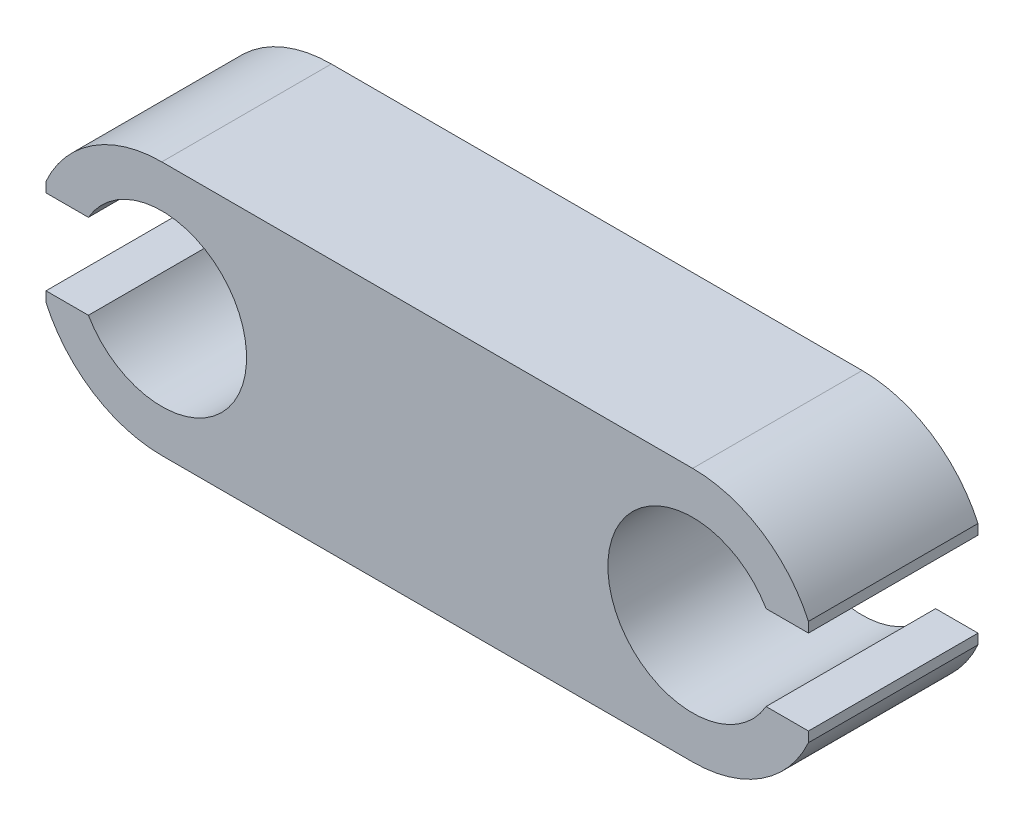
from build123d import *

# Parameters (mm, degrees)
SKETCH_1_R          = 1.5
EXTRUDE_1_DEPTH     = 2
CUT_EXTRUDE_1_DEPTH = 3


with BuildPart() as part:
    # 草图1 → 凸台-拉伸1 (new body)
    with BuildSketch(Plane.XY):
        with Locations((-3.13109105, 0)):
            Circle(SKETCH_1_R)
        with BuildLine():
            Line((3.13109105, 1.5), (-3.13109105, 1.5))
            ThreePointArc((-3.13109105, 1.5), (-2.070430878, 1.060660172), (-1.63109105, 0))
            ThreePointArc((-1.63109105, 0), (-2.070430878, -1.060660172), (-3.13109105, -1.5))
            Line((-3.13109105, -1.5), (3.13109105, -1.5))
            ThreePointArc((3.13109105, -1.5), (1.63109105, 0), (3.13109105, 1.5))
        make_face()
        with Locations((3.13109105, 0)):
            Circle(SKETCH_1_R)
    extrude(amount=EXTRUDE_1_DEPTH)

    # 草图2 → 切除-拉伸1 (cut)
    with BuildSketch(Plane.XY.offset(2)):
        with BuildLine():
            Line((-3.997116454, -0.5), (-4.497116454, -0.5))
            Line((-4.497116454, -0.5), (-4.497116454, -0.619656837))
            ThreePointArc((-4.497116454, -0.619656837), (-4.63109105, 0), (-4.497116454, 0.619656837))
            Line((-4.497116454, 0.619656837), (-4.497116454, 0.5))
            Line((-4.497116454, 0.5), (-3.997116454, 0.5))
            ThreePointArc((-3.997116454, 0.5), (-2.13109105, 0), (-3.997116454, -0.5))
        make_face()
        with BuildLine():
            Line((3.997116454, 0.5), (4.497116454, 0.5))
            Line((4.497116454, 0.5), (4.497116454, 0.619656837))
            ThreePointArc((4.497116454, 0.619656837), (4.63109105, 0), (4.497116454, -0.619656837))
            Line((4.497116454, -0.619656837), (4.497116454, -0.5))
            Line((4.497116454, -0.5), (3.997116454, -0.5))
            ThreePointArc((3.997116454, -0.5), (2.13109105, 0), (3.997116454, 0.5))
        make_face()
    extrude(amount=-CUT_EXTRUDE_1_DEPTH, mode=Mode.SUBTRACT)


solid = part.part
